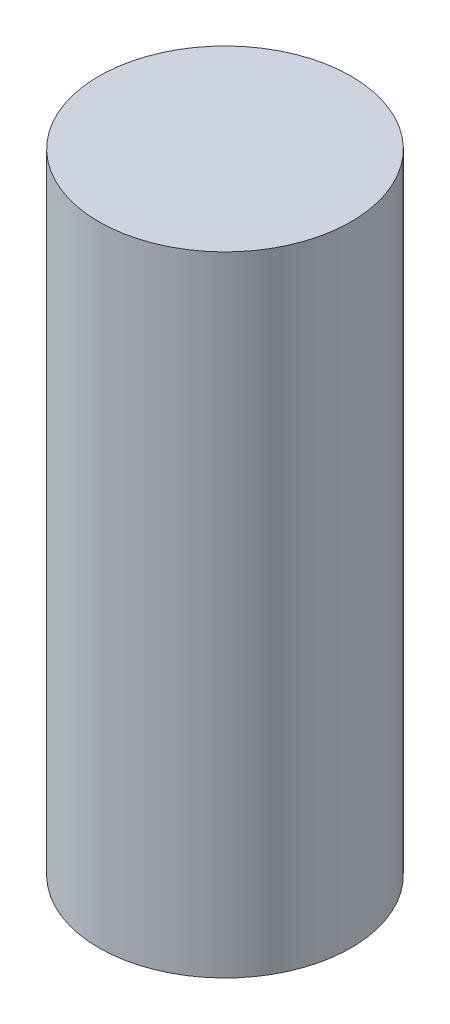
from build123d import *

# Parameters (mm, degrees)
SKETCH2_R           = 3.10515
BOSS_EXTRUDE1_DEPTH = 15.4813


with BuildPart() as part:
    # Sketch2 → Boss-Extrude1 (new body)
    with BuildSketch(Plane(origin=(0, 0, 0), x_dir=(1, 0, 0), z_dir=(0, 1, 0))):
        Circle(SKETCH2_R)
    extrude(amount=BOSS_EXTRUDE1_DEPTH)


solid = part.part
